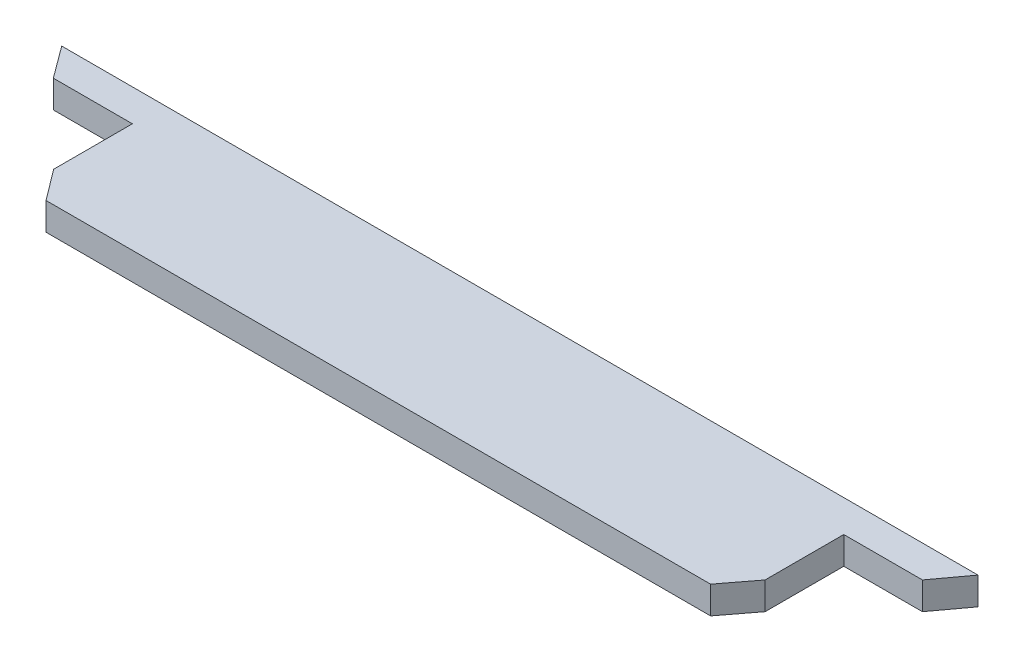
from build123d import *

# Parameters (mm, degrees)
EXTRUDE_1_DEPTH = 70


with BuildPart() as part:
    # 草图1 → 凸台-拉伸1 (new body)
    with BuildSketch(Plane(origin=(0, 0, 0), x_dir=(1, 0, 0), z_dir=(0, 1, 0))):
        Polygon((-1226.000639084, 113.615915427), (1103.964935241, 113.615915427), (1043.964935241, 32.273003651), (843.964935241, 32.273003651), (843.964935241, -167.726996349), (783.964935241, -246.384084573), (-906.000639084, -246.384084573), (-965.035064759, -167.726996349), (-965.035064759, 32.273003651), (-1166.000639084, 32.273003651), align=None)
    extrude(amount=EXTRUDE_1_DEPTH)


solid = part.part
